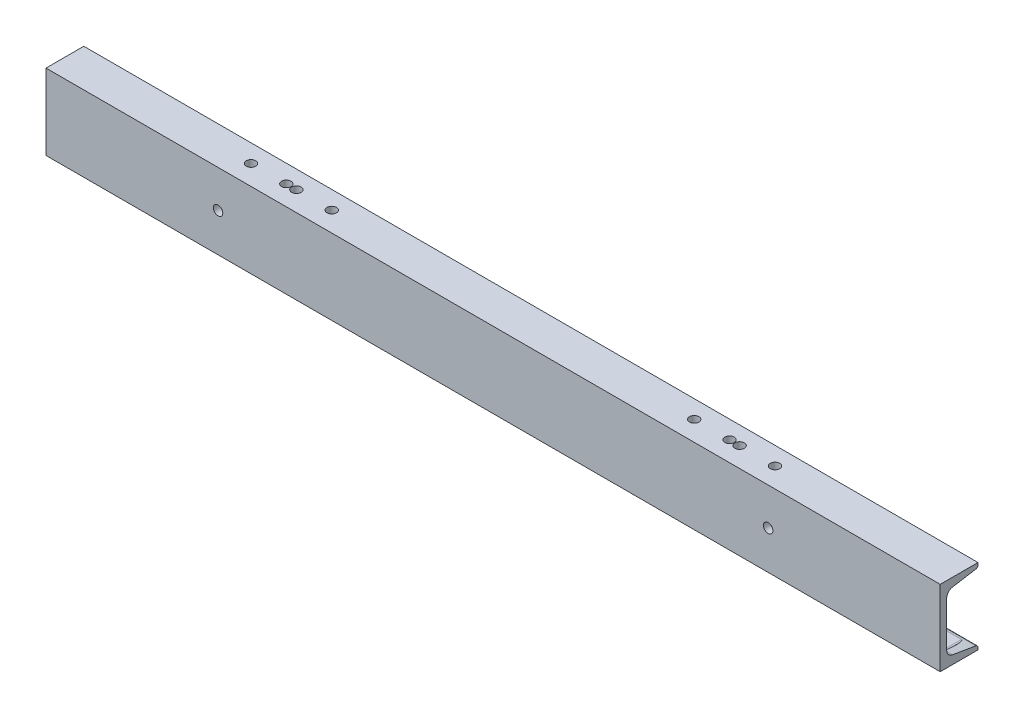
from build123d import *

# Parameters (mm, degrees)
STRUCTURAL_MEMBER1_DEPTH = 900
SKETCH12_R               = 4.7625
CUT_EXTRUDE1_DEPTH       = 454.210052427
CUT_EXTRUDE2_DEPTH       = 40
SKETCH16_R               = 4.7625
CUT_EXTRUDE3_DEPTH       = 454.210052526
SKETCH17_R               = 4.7625
CUT_EXTRUDE4_DEPTH       = 454.210052526


with BuildPart() as part:
    # Sketch11 → Structural Member1 (new body)
    with BuildSketch(Plane(origin=(-450, 0, 0), x_dir=(0, 0, -1), z_dir=(1, 0, 0))):
        with BuildLine():
            Line((0, -38.1), (0, 38.1))
            Line((0, 38.1), (38.0492, 38.1))
            Line((38.0492, 38.1), (38.0492, 35.942335136))
            ThreePointArc((38.0492, 35.942335136), (37.447280466, 34.300554363), (35.926803066, 33.436899509))
            Line((35.926803066, 33.436899509), (12.283671721, 29.496090157))
            ThreePointArc((12.283671721, 29.496090157), (8.178382741, 27.164222052), (6.5532, 22.731413966))
            Line((6.5532, 22.731413966), (6.5532, -22.731413966))
            ThreePointArc((6.5532, -22.731413966), (8.178382741, -27.164222052), (12.283671721, -29.496090157))
            Line((12.283671721, -29.496090157), (35.926803066, -33.436899509))
            ThreePointArc((35.926803066, -33.436899509), (37.447280466, -34.300554363), (38.0492, -35.942335136))
            Line((38.0492, -35.942335136), (38.0492, -38.1))
            Line((38.0492, -38.1), (0, -38.1))
        make_face()
    extrude(amount=STRUCTURAL_MEMBER1_DEPTH)

    # Sketch12 → Cut-Extrude1 (cut, through all)
    with BuildSketch(Plane(origin=(0, 0, 0), x_dir=(1, 0, 0), z_dir=(0, 1, 0))):
        with Locations(Location((-425, 20, 0), (0, 0, 270))):
            Circle(SKETCH12_R)
        with Locations(Location((425, 20, 0), (0, 0, 270))):
            Circle(SKETCH12_R)
    extrude(amount=-CUT_EXTRUDE1_DEPTH, mode=Mode.SUBTRACT)

    # Sketch15 → Cut-Extrude2 (cut)
    with BuildSketch(Plane(origin=(0, 0, -6.5532), x_dir=(-1, 0, 0), z_dir=(0, 0, -1))):
        with BuildLine():
            Line((-412.5, -33.1), (-437.5, -33.1))
            ThreePointArc((-437.5, -33.1), (-442.5, -28.1), (-437.5, -23.1))
            Line((-437.5, -23.1), (-412.5, -23.1))
            ThreePointArc((-412.5, -23.1), (-407.5, -28.1), (-412.5, -33.1))
        make_face()
        with BuildLine():
            Line((412.5, -33.1), (437.5, -33.1))
            ThreePointArc((437.5, -33.1), (442.5, -28.1), (437.5, -23.1))
            Line((437.5, -23.1), (412.5, -23.1))
            ThreePointArc((412.5, -23.1), (407.5, -28.1), (412.5, -33.1))
        make_face()
    extrude(amount=CUT_EXTRUDE2_DEPTH, mode=Mode.SUBTRACT)

    # Sketch16 → Cut-Extrude3 (cut, through all)
    with BuildSketch(Plane(origin=(0, 0, 0), x_dir=(1, 0, 0), z_dir=(0, 1, 0))):
        with Locations(Location((-263.7, 20, 0), (0, 0, 270))):
            Circle(SKETCH16_R)
        with Locations(Location((-228.1, 20, 0), (0, 0, 270))):
            Circle(SKETCH16_R)
        with Locations(Location((228.1, 20, 0), (0, 0, 90))):
            Circle(SKETCH16_R)
        with Locations(Location((263.7, 20, 0), (0, 0, 90))):
            Circle(SKETCH16_R)
        with Locations(Location((-218, 20, 0), (0, 0, 270))):
            Circle(SKETCH16_R)
        with Locations(Location((-182.4, 20, 0), (0, 0, 270))):
            Circle(SKETCH16_R)
        with Locations(Location((182.4, 20, 0), (0, 0, 90))):
            Circle(SKETCH16_R)
        with Locations(Location((218, 20, 0), (0, 0, 90))):
            Circle(SKETCH16_R)
    extrude(amount=CUT_EXTRUDE3_DEPTH, mode=Mode.SUBTRACT)

    # Sketch17 → Cut-Extrude4 (cut, through all)
    with BuildSketch(Plane.XY):
        with Locations((276.8375, 0.6)):
            Circle(SKETCH17_R)
        with Locations((-276.8375, 0.6)):
            Circle(SKETCH17_R)
    extrude(amount=-CUT_EXTRUDE4_DEPTH, mode=Mode.SUBTRACT)


solid = part.part
